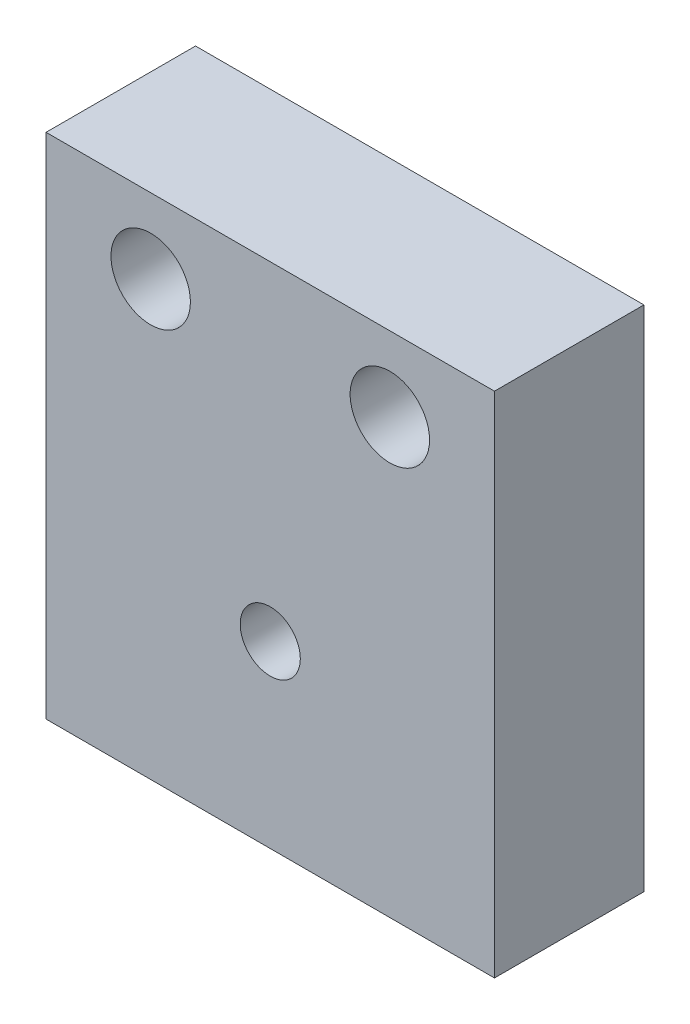
from build123d import *

# Parameters (mm, degrees)
SKETCH1_W                        = 38.1
SKETCH1_H                        = 43.18
BOSS_EXTRUDE1_DEPTH              = 12.7
F_17_64_0_26563_DIAMETER_HOLE1_D = 6.747002
F_1_4_20_TAPPED_HOLE1_D          = 5.1054
F_1_4_20_TAPPED_HOLE1_DEPTH      = 12.7


with BuildPart() as part:
    # Sketch1 → Boss-Extrude1 (new body)
    with BuildSketch(Plane.XY):
        with Locations((19.05, 21.59)):
            Rectangle(SKETCH1_W, SKETCH1_H)
    extrude(amount=-BOSS_EXTRUDE1_DEPTH)

    # 17/64 (0.26563) Diameter Hole1 (through all)
    with Locations(Plane(origin=(29.21, 36.83, 0), x_dir=(1, 0, 0), z_dir=(0, 0, 1))):
        with Locations((0, 0), (-20.32, 0)):
            Hole(F_17_64_0_26563_DIAMETER_HOLE1_D / 2)

    # 1/4-20 Tapped Hole1
    with Locations(Plane.XY):
        with Locations((19.05, 15.24)):
            Hole(F_1_4_20_TAPPED_HOLE1_D / 2, depth=F_1_4_20_TAPPED_HOLE1_DEPTH)


solid = part.part
